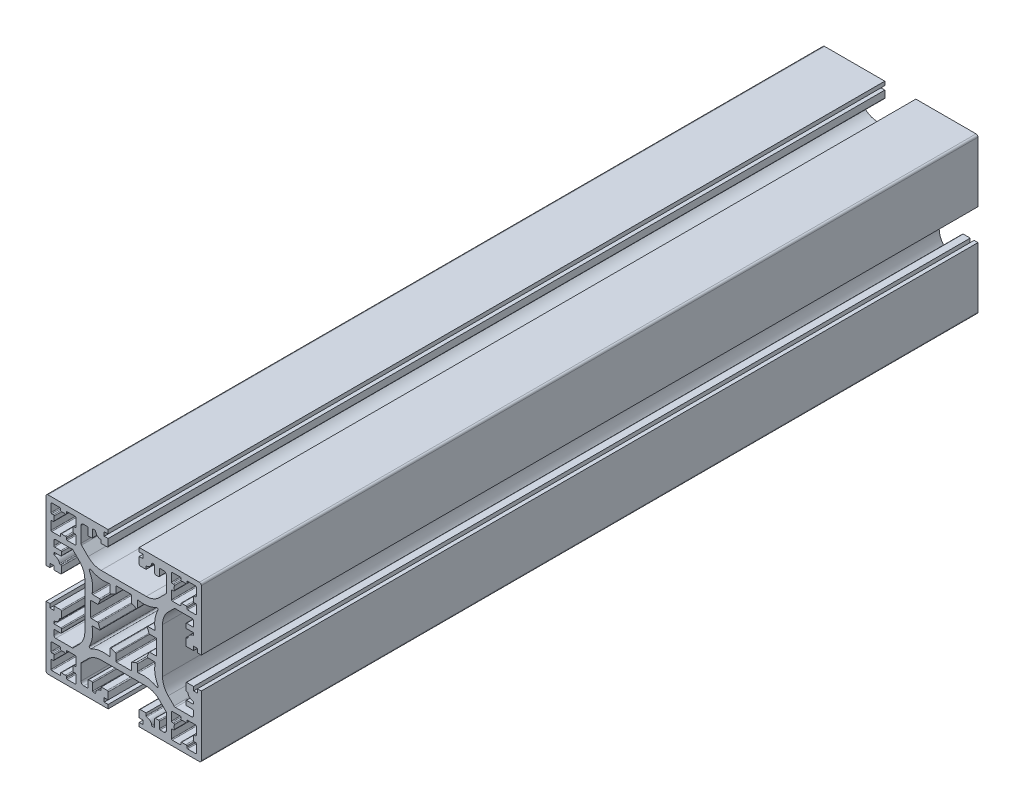
from build123d import *

# Parameters (mm, degrees)
EXTRUDE1_DEPTH = 200


with BuildPart() as part:
    # Sketch1 → Extrude1 (new body)
    with BuildSketch(Plane.XY):
        with BuildLine():
            Line((-18, 9.4), (-18, 10.5))
            ThreePointArc((-18, 10.5), (-17.853553391, 10.853553391), (-17.5, 11))
            Line((-17.5, 11), (-16.25, 11))
            Line((-16.25, 11), (-13.328427125, 11))
            ThreePointArc((-13.328427125, 11), (-13.137085409, 10.961939766), (-12.974873734, 10.853553391))
            Line((-12.974873734, 10.853553391), (-11.464466094, 9.343145751))
            ThreePointArc((-11.464466094, 9.343145751), (-10.380602337, 7.721029006), (-10, 5.807611845))
            Line((-10, 5.807611845), (-10, -5.807611845))
            ThreePointArc((-10, -5.807611845), (-10.380602337, -7.721029006), (-11.464466094, -9.343145751))
            Line((-11.464466094, -9.343145751), (-12.974873734, -10.853553391))
            ThreePointArc((-12.974873734, -10.853553391), (-13.137085409, -10.961939766), (-13.328427125, -11))
            Line((-13.328427125, -11), (-16.25, -11))
            Line((-16.25, -11), (-17.5, -11))
            ThreePointArc((-17.5, -11), (-17.853553391, -10.853553391), (-18, -10.5))
            Line((-18, -10.5), (-18, -9.4))
            ThreePointArc((-18, -9.4), (-17.941421356, -9.258578644), (-17.8, -9.2))
            Line((-17.8, -9.2), (-16.2, -9.2))
            ThreePointArc((-16.2, -9.2), (-16.058578644, -9.141421356), (-16, -9))
            Line((-16, -9), (-16, -8.2))
            ThreePointArc((-16, -8.2), (-16.058578644, -8.058578644), (-16.2, -8))
            Line((-16.2, -8), (-17.8, -8))
            ThreePointArc((-17.8, -8), (-17.941421356, -7.941421356), (-18, -7.8))
            Line((-18, -7.8), (-18, -7.531789047))
            ThreePointArc((-18, -7.531789047), (-17.949481595, -7.398915976), (-17.823447471, -7.333168262))
            ThreePointArc((-17.823447471, -7.333168262), (-16.983327357, -6.948573625), (-16.525924554, -6.145767599))
            ThreePointArc((-16.525924554, -6.145767599), (-16.456281354, -6.03147519), (-16.330156521, -5.986692865))
            Line((-16.330156521, -5.986692865), (-16.2, -5.986692865))
            ThreePointArc((-16.2, -5.986692865), (-16.058578644, -5.928114221), (-16, -5.786692865))
            Line((-16, -5.786692865), (-16, -4.5))
            Line((-16, -4.5), (-16, -4.2))
            ThreePointArc((-16, -4.2), (-16.058578644, -4.058578644), (-16.2, -4))
            Line((-16.2, -4), (-16.5, -4))
            Line((-16.5, -4), (-18, -4))
            Line((-18, -4), (-18, -5))
            Line((-18, -5), (-19, -5))
            Line((-19, -5), (-19, -4))
            Line((-19, -4), (-19.5, -4))
            Line((-19.5, -4), (-20, -4))
            Line((-20, -4), (-20, -4.5))
            Line((-20, -4.5), (-20, -19.5))
            ThreePointArc((-20, -19.5), (-19.853553391, -19.853553391), (-19.5, -20))
            Line((-19.5, -20), (-4, -20))
            Line((-4, -20), (-4, -19))
            Line((-4, -19), (-5, -19))
            Line((-5, -19), (-5, -18))
            Line((-5, -18), (-4, -18))
            Line((-4, -18), (-4, -16.25))
            ThreePointArc((-4, -16.25), (-4.073223305, -16.073223305), (-4.25, -16))
            Line((-4.25, -16), (-5.775096326, -16))
            Line((-5.775096326, -16), (-5.775096326, -16.63645073))
            ThreePointArc((-5.775096326, -16.63645073), (-5.828592677, -16.772600209), (-5.960463134, -16.835914686))
            ThreePointArc((-5.960463134, -16.835914686), (-6.800732332, -17.206772841), (-7.216966157, -18.025514253))
            ThreePointArc((-7.216966157, -18.025514253), (-7.283238985, -18.15017132), (-7.415332039, -18.2))
            Line((-7.415332039, -18.2), (-7.8, -18.2))
            ThreePointArc((-7.8, -18.2), (-7.941421356, -18.141421356), (-8, -18))
            Line((-8, -18), (-8, -16.2))
            ThreePointArc((-8, -16.2), (-8.058578644, -16.058578644), (-8.2, -16))
            Line((-8.2, -16), (-9, -16))
            ThreePointArc((-9, -16), (-9.141421356, -16.058578644), (-9.2, -16.2))
            Line((-9.2, -16.2), (-9.2, -17.8))
            ThreePointArc((-9.2, -17.8), (-9.258578644, -17.941421356), (-9.4, -18))
            Line((-9.4, -18), (-10.3, -18))
            ThreePointArc((-10.3, -18), (-10.794974747, -17.794974747), (-11, -17.3))
            Line((-11, -17.3), (-11, -13.431980515))
            ThreePointArc((-11, -13.431980515), (-10.961939766, -13.240638799), (-10.853553391, -13.078427125))
            Line((-10.853553391, -13.078427125), (-9.166369055, -11.391242789))
            ThreePointArc((-9.166369055, -11.391242789), (-7.625358148, -10.361572221), (-5.807611845, -10))
            Line((-5.807611845, -10), (5.807611845, -10))
            ThreePointArc((5.807611845, -10), (7.625358148, -10.361572221), (9.166369055, -11.391242789))
            Line((9.166369055, -11.391242789), (10.853553391, -13.078427125))
            ThreePointArc((10.853553391, -13.078427125), (10.961939766, -13.240638799), (11, -13.431980515))
            Line((11, -13.431980515), (11, -17.3))
            ThreePointArc((11, -17.3), (10.794974747, -17.794974747), (10.3, -18))
            Line((10.3, -18), (9.4, -18))
            ThreePointArc((9.4, -18), (9.258578644, -17.941421356), (9.2, -17.8))
            Line((9.2, -17.8), (9.2, -16.2))
            ThreePointArc((9.2, -16.2), (9.141421356, -16.058578644), (9, -16))
            Line((9, -16), (8.2, -16))
            ThreePointArc((8.2, -16), (8.058578644, -16.058578644), (8, -16.2))
            Line((8, -16.2), (8, -18))
            ThreePointArc((8, -18), (7.941421356, -18.141421356), (7.8, -18.2))
            Line((7.8, -18.2), (7.415332039, -18.2))
            ThreePointArc((7.415332039, -18.2), (7.283238985, -18.15017132), (7.216966157, -18.025514253))
            ThreePointArc((7.216966157, -18.025514253), (6.800732332, -17.206772841), (5.960463134, -16.835914686))
            ThreePointArc((5.960463134, -16.835914686), (5.828592677, -16.772600209), (5.775096326, -16.63645073))
            Line((5.775096326, -16.63645073), (5.775096326, -16))
            Line((5.775096326, -16), (4.25, -16))
            ThreePointArc((4.25, -16), (4.073223305, -16.073223305), (4, -16.25))
            Line((4, -16.25), (4, -18))
            Line((4, -18), (5, -18))
            Line((5, -18), (5, -19))
            Line((5, -19), (4, -19))
            Line((4, -19), (4, -20))
            Line((4, -20), (19.5, -20))
            ThreePointArc((19.5, -20), (19.853553391, -19.853553391), (20, -19.5))
            Line((20, -19.5), (20, -4.5))
            Line((20, -4.5), (20, -4))
            Line((20, -4), (19.5, -4))
            Line((19.5, -4), (19, -4))
            Line((19, -4), (19, -5))
            Line((19, -5), (18, -5))
            Line((18, -5), (18, -4))
            Line((18, -4), (16.5, -4))
            Line((16.5, -4), (16.2, -4))
            ThreePointArc((16.2, -4), (16.058578644, -4.058578644), (16, -4.2))
            Line((16, -4.2), (16, -4.5))
            Line((16, -4.5), (16, -5.786692865))
            ThreePointArc((16, -5.786692865), (16.058578644, -5.928114221), (16.2, -5.986692865))
            Line((16.2, -5.986692865), (16.330156521, -5.986692865))
            ThreePointArc((16.330156521, -5.986692865), (16.456281354, -6.03147519), (16.525924554, -6.145767599))
            ThreePointArc((16.525924554, -6.145767599), (16.983327357, -6.948573625), (17.823447471, -7.333168262))
            ThreePointArc((17.823447471, -7.333168262), (17.949481595, -7.398915976), (18, -7.531789047))
            Line((18, -7.531789047), (18, -7.8))
            ThreePointArc((18, -7.8), (17.941421356, -7.941421356), (17.8, -8))
            Line((17.8, -8), (16.2, -8))
            ThreePointArc((16.2, -8), (16.058578644, -8.058578644), (16, -8.2))
            Line((16, -8.2), (16, -9))
            ThreePointArc((16, -9), (16.058578644, -9.141421356), (16.2, -9.2))
            Line((16.2, -9.2), (17.8, -9.2))
            ThreePointArc((17.8, -9.2), (17.941421356, -9.258578644), (18, -9.4))
            Line((18, -9.4), (18, -10.5))
            ThreePointArc((18, -10.5), (17.853553391, -10.853553391), (17.5, -11))
            Line((17.5, -11), (16.25, -11))
            Line((16.25, -11), (13.328427125, -11))
            ThreePointArc((13.328427125, -11), (13.137085409, -10.961939766), (12.974873734, -10.853553391))
            Line((12.974873734, -10.853553391), (11.464466094, -9.343145751))
            ThreePointArc((11.464466094, -9.343145751), (10.380602337, -7.721029006), (10, -5.807611845))
            Line((10, -5.807611845), (10, 5.807611845))
            ThreePointArc((10, 5.807611845), (10.380602337, 7.721029006), (11.464466094, 9.343145751))
            Line((11.464466094, 9.343145751), (12.974873734, 10.853553391))
            ThreePointArc((12.974873734, 10.853553391), (13.137085409, 10.961939766), (13.328427125, 11))
            Line((13.328427125, 11), (16.25, 11))
            Line((16.25, 11), (17.5, 11))
            ThreePointArc((17.5, 11), (17.853553391, 10.853553391), (18, 10.5))
            Line((18, 10.5), (18, 9.4))
            ThreePointArc((18, 9.4), (17.941421356, 9.258578644), (17.8, 9.2))
            Line((17.8, 9.2), (16.2, 9.2))
            ThreePointArc((16.2, 9.2), (16.058578644, 9.141421356), (16, 9))
            Line((16, 9), (16, 8.2))
            ThreePointArc((16, 8.2), (16.058578644, 8.058578644), (16.2, 8))
            Line((16.2, 8), (17.8, 8))
            ThreePointArc((17.8, 8), (17.941421356, 7.941421356), (18, 7.8))
            Line((18, 7.8), (18, 7.531789047))
            ThreePointArc((18, 7.531789047), (17.949481595, 7.398915976), (17.823447471, 7.333168262))
            ThreePointArc((17.823447471, 7.333168262), (16.983327357, 6.948573625), (16.525924554, 6.145767599))
            ThreePointArc((16.525924554, 6.145767599), (16.456281354, 6.03147519), (16.330156521, 5.986692865))
            Line((16.330156521, 5.986692865), (16.2, 5.986692865))
            ThreePointArc((16.2, 5.986692865), (16.058578644, 5.928114221), (16, 5.786692865))
            Line((16, 5.786692865), (16, 4.5))
            Line((16, 4.5), (16, 4.2))
            ThreePointArc((16, 4.2), (16.058578644, 4.058578644), (16.2, 4))
            Line((16.2, 4), (16.5, 4))
            Line((16.5, 4), (18, 4))
            Line((18, 4), (18, 5))
            Line((18, 5), (19, 5))
            Line((19, 5), (19, 4))
            Line((19, 4), (19.5, 4))
            Line((19.5, 4), (20, 4))
            Line((20, 4), (20, 4.5))
            Line((20, 4.5), (20, 19.5))
            ThreePointArc((20, 19.5), (19.853553391, 19.853553391), (19.5, 20))
            Line((19.5, 20), (4, 20))
            Line((4, 20), (4, 19))
            Line((4, 19), (5, 19))
            Line((5, 19), (5, 18))
            Line((5, 18), (4, 18))
            Line((4, 18), (4, 16.25))
            ThreePointArc((4, 16.25), (4.073223305, 16.073223305), (4.25, 16))
            Line((4.25, 16), (5.775096326, 16))
            Line((5.775096326, 16), (5.775096326, 16.63645073))
            ThreePointArc((5.775096326, 16.63645073), (5.828592677, 16.772600209), (5.960463134, 16.835914686))
            ThreePointArc((5.960463134, 16.835914686), (6.800732332, 17.206772841), (7.216966157, 18.025514253))
            ThreePointArc((7.216966157, 18.025514253), (7.283238985, 18.15017132), (7.415332039, 18.2))
            Line((7.415332039, 18.2), (7.8, 18.2))
            ThreePointArc((7.8, 18.2), (7.941421356, 18.141421356), (8, 18))
            Line((8, 18), (8, 16.2))
            ThreePointArc((8, 16.2), (8.058578644, 16.058578644), (8.2, 16))
            Line((8.2, 16), (9, 16))
            ThreePointArc((9, 16), (9.141421356, 16.058578644), (9.2, 16.2))
            Line((9.2, 16.2), (9.2, 17.8))
            ThreePointArc((9.2, 17.8), (9.258578644, 17.941421356), (9.4, 18))
            Line((9.4, 18), (10.3, 18))
            ThreePointArc((10.3, 18), (10.794974747, 17.794974747), (11, 17.3))
            Line((11, 17.3), (11, 13.431980515))
            ThreePointArc((11, 13.431980515), (10.961939766, 13.240638799), (10.853553391, 13.078427125))
            Line((10.853553391, 13.078427125), (9.166369055, 11.391242789))
            ThreePointArc((9.166369055, 11.391242789), (7.625358148, 10.361572221), (5.807611845, 10))
            Line((5.807611845, 10), (-5.807611845, 10))
            ThreePointArc((-5.807611845, 10), (-7.625358148, 10.361572221), (-9.166369055, 11.391242789))
            Line((-9.166369055, 11.391242789), (-10.853553391, 13.078427125))
            ThreePointArc((-10.853553391, 13.078427125), (-10.961939766, 13.240638799), (-11, 13.431980515))
            Line((-11, 13.431980515), (-11, 17.3))
            ThreePointArc((-11, 17.3), (-10.794974747, 17.794974747), (-10.3, 18))
            Line((-10.3, 18), (-9.4, 18))
            ThreePointArc((-9.4, 18), (-9.258578644, 17.941421356), (-9.2, 17.8))
            Line((-9.2, 17.8), (-9.2, 16.2))
            ThreePointArc((-9.2, 16.2), (-9.141421356, 16.058578644), (-9, 16))
            Line((-9, 16), (-8.2, 16))
            ThreePointArc((-8.2, 16), (-8.058578644, 16.058578644), (-8, 16.2))
            Line((-8, 16.2), (-8, 18))
            ThreePointArc((-8, 18), (-7.941421356, 18.141421356), (-7.8, 18.2))
            Line((-7.8, 18.2), (-7.415332039, 18.2))
            ThreePointArc((-7.415332039, 18.2), (-7.283238985, 18.15017132), (-7.216966157, 18.025514253))
            ThreePointArc((-7.216966157, 18.025514253), (-6.800732332, 17.206772841), (-5.960463134, 16.835914686))
            ThreePointArc((-5.960463134, 16.835914686), (-5.828592677, 16.772600209), (-5.775096326, 16.63645073))
            Line((-5.775096326, 16.63645073), (-5.775096326, 16))
            Line((-5.775096326, 16), (-4.25, 16))
            ThreePointArc((-4.25, 16), (-4.073223305, 16.073223305), (-4, 16.25))
            Line((-4, 16.25), (-4, 18))
            Line((-4, 18), (-5, 18))
            Line((-5, 18), (-5, 19))
            Line((-5, 19), (-4, 19))
            Line((-4, 19), (-4, 20))
            Line((-4, 20), (-19.5, 20))
            ThreePointArc((-19.5, 20), (-19.853553391, 19.853553391), (-20, 19.5))
            Line((-20, 19.5), (-20, 4.5))
            Line((-20, 4.5), (-20, 4))
            Line((-20, 4), (-19.5, 4))
            Line((-19.5, 4), (-19, 4))
            Line((-19, 4), (-19, 5))
            Line((-19, 5), (-18, 5))
            Line((-18, 5), (-18, 4))
            Line((-18, 4), (-16.5, 4))
            Line((-16.5, 4), (-16.2, 4))
            ThreePointArc((-16.2, 4), (-16.058578644, 4.058578644), (-16, 4.2))
            Line((-16, 4.2), (-16, 4.5))
            Line((-16, 4.5), (-16, 5.786692865))
            ThreePointArc((-16, 5.786692865), (-16.058578644, 5.928114221), (-16.2, 5.986692865))
            Line((-16.2, 5.986692865), (-16.330156521, 5.986692865))
            ThreePointArc((-16.330156521, 5.986692865), (-16.456281354, 6.03147519), (-16.525924554, 6.145767599))
            ThreePointArc((-16.525924554, 6.145767599), (-16.983327357, 6.948573625), (-17.823447471, 7.333168262))
            ThreePointArc((-17.823447471, 7.333168262), (-17.949481595, 7.398915976), (-18, 7.531789047))
            Line((-18, 7.531789047), (-18, 7.8))
            ThreePointArc((-18, 7.8), (-17.941421356, 7.941421356), (-17.8, 8))
            Line((-17.8, 8), (-16.2, 8))
            ThreePointArc((-16.2, 8), (-16.058578644, 8.058578644), (-16, 8.2))
            Line((-16, 8.2), (-16, 9))
            ThreePointArc((-16, 9), (-16.058578644, 9.141421356), (-16.2, 9.2))
            Line((-16.2, 9.2), (-17.8, 9.2))
            ThreePointArc((-17.8, 9.2), (-17.941421356, 9.258578644), (-18, 9.4))
        make_face()
        with BuildLine():
            Line((1.8, 8.5), (-1.8, 8.5))
            ThreePointArc((-1.8, 8.5), (-1.941421356, 8.441421356), (-2, 8.3))
            Line((-2, 8.3), (-2, 6.697947447))
            ThreePointArc((-2, 6.697947447), (-2.038008844, 6.580649257), (-2.137588652, 6.507934753))
            ThreePointArc((-2.137588652, 6.507934753), (-2.681640734, 6.303277162), (-3.206382979, 6.053231219))
            ThreePointArc((-3.206382979, 6.053231219), (-3.403142125, 6.05861533), (-3.5, 6.229967897))
            Line((-3.5, 6.229967897), (-3.5, 7.919878854))
            ThreePointArc((-3.5, 7.919878854), (-3.572914811, 8.074311217), (-3.738493547, 8.116139514))
            ThreePointArc((-3.738493547, 8.116139514), (-6.145812945, 8.065992143), (-8.427707326, 8.834535885))
            ThreePointArc((-8.427707326, 8.834535885), (-8.783065344, 8.783065344), (-8.834535885, 8.427707326))
            ThreePointArc((-8.834535885, 8.427707326), (-8.065992143, 6.145812945), (-8.116139514, 3.738493547))
            ThreePointArc((-8.116139514, 3.738493547), (-8.074311217, 3.572914811), (-7.919878854, 3.5))
            Line((-7.919878854, 3.5), (-6.229967897, 3.5))
            ThreePointArc((-6.229967897, 3.5), (-6.05861533, 3.403142125), (-6.053231219, 3.206382979))
            ThreePointArc((-6.053231219, 3.206382979), (-6.303277162, 2.681640734), (-6.507934753, 2.137588652))
            ThreePointArc((-6.507934753, 2.137588652), (-6.580649257, 2.038008844), (-6.697947447, 2))
            Line((-6.697947447, 2), (-8.3, 2))
            ThreePointArc((-8.3, 2), (-8.441421356, 1.941421356), (-8.5, 1.8))
            Line((-8.5, 1.8), (-8.5, -1.8))
            ThreePointArc((-8.5, -1.8), (-8.441421356, -1.941421356), (-8.3, -2))
            Line((-8.3, -2), (-6.697947447, -2))
            ThreePointArc((-6.697947447, -2), (-6.580649257, -2.038008844), (-6.507934753, -2.137588652))
            ThreePointArc((-6.507934753, -2.137588652), (-6.303277162, -2.681640734), (-6.053231219, -3.206382979))
            ThreePointArc((-6.053231219, -3.206382979), (-6.05861533, -3.403142125), (-6.229967897, -3.5))
            Line((-6.229967897, -3.5), (-7.919878854, -3.5))
            ThreePointArc((-7.919878854, -3.5), (-8.074311217, -3.572914811), (-8.116139514, -3.738493547))
            ThreePointArc((-8.116139514, -3.738493547), (-8.065992143, -6.145812945), (-8.834535885, -8.427707326))
            ThreePointArc((-8.834535885, -8.427707326), (-8.783065344, -8.783065344), (-8.427707326, -8.834535885))
            ThreePointArc((-8.427707326, -8.834535885), (-6.145812945, -8.065992143), (-3.738493547, -8.116139514))
            ThreePointArc((-3.738493547, -8.116139514), (-3.572914811, -8.074311217), (-3.5, -7.919878854))
            Line((-3.5, -7.919878854), (-3.5, -6.229967897))
            ThreePointArc((-3.5, -6.229967897), (-3.403142125, -6.05861533), (-3.206382979, -6.053231219))
            ThreePointArc((-3.206382979, -6.053231219), (-2.681640734, -6.303277162), (-2.137588652, -6.507934753))
            ThreePointArc((-2.137588652, -6.507934753), (-2.038008844, -6.580649257), (-2, -6.697947447))
            Line((-2, -6.697947447), (-2, -8.3))
            ThreePointArc((-2, -8.3), (-1.941421356, -8.441421356), (-1.8, -8.5))
            Line((-1.8, -8.5), (1.8, -8.5))
            ThreePointArc((1.8, -8.5), (1.941421356, -8.441421356), (2, -8.3))
            Line((2, -8.3), (2, -6.697947447))
            ThreePointArc((2, -6.697947447), (2.038008844, -6.580649257), (2.137588652, -6.507934753))
            ThreePointArc((2.137588652, -6.507934753), (2.681640734, -6.303277162), (3.206382979, -6.053231219))
            ThreePointArc((3.206382979, -6.053231219), (3.403142125, -6.05861533), (3.5, -6.229967897))
            Line((3.5, -6.229967897), (3.5, -7.919878854))
            ThreePointArc((3.5, -7.919878854), (3.572914811, -8.074311217), (3.738493547, -8.116139514))
            ThreePointArc((3.738493547, -8.116139514), (6.145812945, -8.065992143), (8.427707326, -8.834535885))
            ThreePointArc((8.427707326, -8.834535885), (8.783065344, -8.783065344), (8.834535885, -8.427707326))
            ThreePointArc((8.834535885, -8.427707326), (8.065992143, -6.145812945), (8.116139514, -3.738493547))
            ThreePointArc((8.116139514, -3.738493547), (8.074311217, -3.572914811), (7.919878854, -3.5))
            Line((7.919878854, -3.5), (6.229967897, -3.5))
            ThreePointArc((6.229967897, -3.5), (6.05861533, -3.403142125), (6.053231219, -3.206382979))
            ThreePointArc((6.053231219, -3.206382979), (6.303277162, -2.681640734), (6.507934753, -2.137588652))
            ThreePointArc((6.507934753, -2.137588652), (6.580649257, -2.038008844), (6.697947447, -2))
            Line((6.697947447, -2), (8.3, -2))
            ThreePointArc((8.3, -2), (8.441421356, -1.941421356), (8.5, -1.8))
            Line((8.5, -1.8), (8.5, 1.8))
            ThreePointArc((8.5, 1.8), (8.441421356, 1.941421356), (8.3, 2))
            Line((8.3, 2), (6.697947447, 2))
            ThreePointArc((6.697947447, 2), (6.580649257, 2.038008844), (6.507934753, 2.137588652))
            ThreePointArc((6.507934753, 2.137588652), (6.303277162, 2.681640734), (6.053231219, 3.206382979))
            ThreePointArc((6.053231219, 3.206382979), (6.05861533, 3.403142125), (6.229967897, 3.5))
            Line((6.229967897, 3.5), (7.919878854, 3.5))
            ThreePointArc((7.919878854, 3.5), (8.074311217, 3.572914811), (8.116139514, 3.738493547))
            ThreePointArc((8.116139514, 3.738493547), (8.065992143, 6.145812945), (8.834535885, 8.427707326))
            ThreePointArc((8.834535885, 8.427707326), (8.783065344, 8.783065344), (8.427707326, 8.834535885))
            ThreePointArc((8.427707326, 8.834535885), (6.145812945, 8.065992143), (3.738493547, 8.116139514))
            ThreePointArc((3.738493547, 8.116139514), (3.572914811, 8.074311217), (3.5, 7.919878854))
            Line((3.5, 7.919878854), (3.5, 6.229967897))
            ThreePointArc((3.5, 6.229967897), (3.403142125, 6.05861533), (3.206382979, 6.053231219))
            ThreePointArc((3.206382979, 6.053231219), (2.681640734, 6.303277162), (2.137588652, 6.507934753))
            ThreePointArc((2.137588652, 6.507934753), (2.038008844, 6.580649257), (2, 6.697947447))
            Line((2, 6.697947447), (2, 8.3))
            ThreePointArc((2, 8.3), (1.941421356, 8.441421356), (1.8, 8.5))
        make_face(mode=Mode.SUBTRACT)
        with BuildLine():
            Line((-18.5, 18.7), (-16.45, 18.7))
            ThreePointArc((-16.45, 18.7), (-16.308578644, 18.641421356), (-16.25, 18.5))
            Line((-16.25, 18.5), (-16.25, 18.143387978))
            ThreePointArc((-16.25, 18.143387978), (-16.176197963, 17.988229755), (-16.009259259, 17.947581461))
            ThreePointArc((-16.009259259, 17.947581461), (-15.5, 18), (-14.990740741, 17.947581461))
            ThreePointArc((-14.990740741, 17.947581461), (-14.823802037, 17.988229755), (-14.75, 18.143387978))
            Line((-14.75, 18.143387978), (-14.75, 18.5))
            ThreePointArc((-14.75, 18.5), (-14.691421356, 18.641421356), (-14.55, 18.7))
            Line((-14.55, 18.7), (-12.5, 18.7))
            ThreePointArc((-12.5, 18.7), (-12.358578644, 18.641421356), (-12.3, 18.5))
            Line((-12.3, 18.5), (-12.3, 16.45))
            ThreePointArc((-12.3, 16.45), (-12.358578644, 16.308578644), (-12.5, 16.25))
            Line((-12.5, 16.25), (-12.856612022, 16.25))
            ThreePointArc((-12.856612022, 16.25), (-13.011770245, 16.176197963), (-13.052418539, 16.009259259))
            ThreePointArc((-13.052418539, 16.009259259), (-13, 15.5), (-13.052418539, 14.990740741))
            ThreePointArc((-13.052418539, 14.990740741), (-13.011770245, 14.823802037), (-12.856612022, 14.75))
            Line((-12.856612022, 14.75), (-12.5, 14.75))
            ThreePointArc((-12.5, 14.75), (-12.358578644, 14.691421356), (-12.3, 14.55))
            Line((-12.3, 14.55), (-12.3, 12.5))
            ThreePointArc((-12.3, 12.5), (-12.358578644, 12.358578644), (-12.5, 12.3))
            Line((-12.5, 12.3), (-14.55, 12.3))
            ThreePointArc((-14.55, 12.3), (-14.691421356, 12.358578644), (-14.75, 12.5))
            Line((-14.75, 12.5), (-14.75, 12.856612022))
            ThreePointArc((-14.75, 12.856612022), (-14.823802037, 13.011770245), (-14.990740741, 13.052418539))
            ThreePointArc((-14.990740741, 13.052418539), (-15.5, 13), (-16.009259259, 13.052418539))
            ThreePointArc((-16.009259259, 13.052418539), (-16.176197963, 13.011770245), (-16.25, 12.856612022))
            Line((-16.25, 12.856612022), (-16.25, 12.5))
            ThreePointArc((-16.25, 12.5), (-16.308578644, 12.358578644), (-16.45, 12.3))
            Line((-16.45, 12.3), (-18.5, 12.3))
            ThreePointArc((-18.5, 12.3), (-18.641421356, 12.358578644), (-18.7, 12.5))
            Line((-18.7, 12.5), (-18.7, 14.55))
            ThreePointArc((-18.7, 14.55), (-18.641421356, 14.691421356), (-18.5, 14.75))
            Line((-18.5, 14.75), (-18.143387978, 14.75))
            ThreePointArc((-18.143387978, 14.75), (-17.988229755, 14.823802037), (-17.947581461, 14.990740741))
            ThreePointArc((-17.947581461, 14.990740741), (-18, 15.5), (-17.947581461, 16.009259259))
            ThreePointArc((-17.947581461, 16.009259259), (-17.988229755, 16.176197963), (-18.143387978, 16.25))
            Line((-18.143387978, 16.25), (-18.5, 16.25))
            ThreePointArc((-18.5, 16.25), (-18.641421356, 16.308578644), (-18.7, 16.45))
            Line((-18.7, 16.45), (-18.7, 18.5))
            ThreePointArc((-18.7, 18.5), (-18.641421356, 18.641421356), (-18.5, 18.7))
        make_face(mode=Mode.SUBTRACT)
        with BuildLine():
            Line((12.3, 14.55), (12.3, 12.5))
            ThreePointArc((12.3, 12.5), (12.358578644, 12.358578644), (12.5, 12.3))
            Line((12.5, 12.3), (14.55, 12.3))
            ThreePointArc((14.55, 12.3), (14.691421356, 12.358578644), (14.75, 12.5))
            Line((14.75, 12.5), (14.75, 12.856612022))
            ThreePointArc((14.75, 12.856612022), (14.823802037, 13.011770245), (14.990740741, 13.052418539))
            ThreePointArc((14.990740741, 13.052418539), (15.5, 13), (16.009259259, 13.052418539))
            ThreePointArc((16.009259259, 13.052418539), (16.176197963, 13.011770245), (16.25, 12.856612022))
            Line((16.25, 12.856612022), (16.25, 12.5))
            ThreePointArc((16.25, 12.5), (16.308578644, 12.358578644), (16.45, 12.3))
            Line((16.45, 12.3), (18.5, 12.3))
            ThreePointArc((18.5, 12.3), (18.641421356, 12.358578644), (18.7, 12.5))
            Line((18.7, 12.5), (18.7, 14.55))
            ThreePointArc((18.7, 14.55), (18.641421356, 14.691421356), (18.5, 14.75))
            Line((18.5, 14.75), (18.143387978, 14.75))
            ThreePointArc((18.143387978, 14.75), (17.988229755, 14.823802037), (17.947581461, 14.990740741))
            ThreePointArc((17.947581461, 14.990740741), (18, 15.5), (17.947581461, 16.009259259))
            ThreePointArc((17.947581461, 16.009259259), (17.988229755, 16.176197963), (18.143387978, 16.25))
            Line((18.143387978, 16.25), (18.5, 16.25))
            ThreePointArc((18.5, 16.25), (18.641421356, 16.308578644), (18.7, 16.45))
            Line((18.7, 16.45), (18.7, 18.5))
            ThreePointArc((18.7, 18.5), (18.641421356, 18.641421356), (18.5, 18.7))
            Line((18.5, 18.7), (16.45, 18.7))
            ThreePointArc((16.45, 18.7), (16.308578644, 18.641421356), (16.25, 18.5))
            Line((16.25, 18.5), (16.25, 18.143387978))
            ThreePointArc((16.25, 18.143387978), (16.176197963, 17.988229755), (16.009259259, 17.947581461))
            ThreePointArc((16.009259259, 17.947581461), (15.5, 18), (14.990740741, 17.947581461))
            ThreePointArc((14.990740741, 17.947581461), (14.823802037, 17.988229755), (14.75, 18.143387978))
            Line((14.75, 18.143387978), (14.75, 18.5))
            ThreePointArc((14.75, 18.5), (14.691421356, 18.641421356), (14.55, 18.7))
            Line((14.55, 18.7), (12.5, 18.7))
            ThreePointArc((12.5, 18.7), (12.358578644, 18.641421356), (12.3, 18.5))
            Line((12.3, 18.5), (12.3, 16.45))
            ThreePointArc((12.3, 16.45), (12.358578644, 16.308578644), (12.5, 16.25))
            Line((12.5, 16.25), (12.856612022, 16.25))
            ThreePointArc((12.856612022, 16.25), (13.011770245, 16.176197963), (13.052418539, 16.009259259))
            ThreePointArc((13.052418539, 16.009259259), (13, 15.5), (13.052418539, 14.990740741))
            ThreePointArc((13.052418539, 14.990740741), (13.011770245, 14.823802037), (12.856612022, 14.75))
            Line((12.856612022, 14.75), (12.5, 14.75))
            ThreePointArc((12.5, 14.75), (12.358578644, 14.691421356), (12.3, 14.55))
        make_face(mode=Mode.SUBTRACT)
        with BuildLine():
            Line((18.5, -18.7), (16.45, -18.7))
            ThreePointArc((16.45, -18.7), (16.308578644, -18.641421356), (16.25, -18.5))
            Line((16.25, -18.5), (16.25, -18.143387978))
            ThreePointArc((16.25, -18.143387978), (16.176197963, -17.988229755), (16.009259259, -17.947581461))
            ThreePointArc((16.009259259, -17.947581461), (15.5, -18), (14.990740741, -17.947581461))
            ThreePointArc((14.990740741, -17.947581461), (14.823802037, -17.988229755), (14.75, -18.143387978))
            Line((14.75, -18.143387978), (14.75, -18.5))
            ThreePointArc((14.75, -18.5), (14.691421356, -18.641421356), (14.55, -18.7))
            Line((14.55, -18.7), (12.5, -18.7))
            ThreePointArc((12.5, -18.7), (12.358578644, -18.641421356), (12.3, -18.5))
            Line((12.3, -18.5), (12.3, -16.45))
            ThreePointArc((12.3, -16.45), (12.358578644, -16.308578644), (12.5, -16.25))
            Line((12.5, -16.25), (12.856612022, -16.25))
            ThreePointArc((12.856612022, -16.25), (13.011770245, -16.176197963), (13.052418539, -16.009259259))
            ThreePointArc((13.052418539, -16.009259259), (13, -15.5), (13.052418539, -14.990740741))
            ThreePointArc((13.052418539, -14.990740741), (13.011770245, -14.823802037), (12.856612022, -14.75))
            Line((12.856612022, -14.75), (12.5, -14.75))
            ThreePointArc((12.5, -14.75), (12.358578644, -14.691421356), (12.3, -14.55))
            Line((12.3, -14.55), (12.3, -12.5))
            ThreePointArc((12.3, -12.5), (12.358578644, -12.358578644), (12.5, -12.3))
            Line((12.5, -12.3), (14.55, -12.3))
            ThreePointArc((14.55, -12.3), (14.691421356, -12.358578644), (14.75, -12.5))
            Line((14.75, -12.5), (14.75, -12.856612022))
            ThreePointArc((14.75, -12.856612022), (14.823802037, -13.011770245), (14.990740741, -13.052418539))
            ThreePointArc((14.990740741, -13.052418539), (15.5, -13), (16.009259259, -13.052418539))
            ThreePointArc((16.009259259, -13.052418539), (16.176197963, -13.011770245), (16.25, -12.856612022))
            Line((16.25, -12.856612022), (16.25, -12.5))
            ThreePointArc((16.25, -12.5), (16.308578644, -12.358578644), (16.45, -12.3))
            Line((16.45, -12.3), (18.5, -12.3))
            ThreePointArc((18.5, -12.3), (18.641421356, -12.358578644), (18.7, -12.5))
            Line((18.7, -12.5), (18.7, -14.55))
            ThreePointArc((18.7, -14.55), (18.641421356, -14.691421356), (18.5, -14.75))
            Line((18.5, -14.75), (18.143387978, -14.75))
            ThreePointArc((18.143387978, -14.75), (17.988229755, -14.823802037), (17.947581461, -14.990740741))
            ThreePointArc((17.947581461, -14.990740741), (18, -15.5), (17.947581461, -16.009259259))
            ThreePointArc((17.947581461, -16.009259259), (17.988229755, -16.176197963), (18.143387978, -16.25))
            Line((18.143387978, -16.25), (18.5, -16.25))
            ThreePointArc((18.5, -16.25), (18.641421356, -16.308578644), (18.7, -16.45))
            Line((18.7, -16.45), (18.7, -18.5))
            ThreePointArc((18.7, -18.5), (18.641421356, -18.641421356), (18.5, -18.7))
        make_face(mode=Mode.SUBTRACT)
        with BuildLine():
            Line((-12.3, -14.55), (-12.3, -12.5))
            ThreePointArc((-12.3, -12.5), (-12.358578644, -12.358578644), (-12.5, -12.3))
            Line((-12.5, -12.3), (-14.55, -12.3))
            ThreePointArc((-14.55, -12.3), (-14.691421356, -12.358578644), (-14.75, -12.5))
            Line((-14.75, -12.5), (-14.75, -12.856612022))
            ThreePointArc((-14.75, -12.856612022), (-14.823802037, -13.011770245), (-14.990740741, -13.052418539))
            ThreePointArc((-14.990740741, -13.052418539), (-15.5, -13), (-16.009259259, -13.052418539))
            ThreePointArc((-16.009259259, -13.052418539), (-16.176197963, -13.011770245), (-16.25, -12.856612022))
            Line((-16.25, -12.856612022), (-16.25, -12.5))
            ThreePointArc((-16.25, -12.5), (-16.308578644, -12.358578644), (-16.45, -12.3))
            Line((-16.45, -12.3), (-18.5, -12.3))
            ThreePointArc((-18.5, -12.3), (-18.641421356, -12.358578644), (-18.7, -12.5))
            Line((-18.7, -12.5), (-18.7, -14.55))
            ThreePointArc((-18.7, -14.55), (-18.641421356, -14.691421356), (-18.5, -14.75))
            Line((-18.5, -14.75), (-18.143387978, -14.75))
            ThreePointArc((-18.143387978, -14.75), (-17.988229755, -14.823802037), (-17.947581461, -14.990740741))
            ThreePointArc((-17.947581461, -14.990740741), (-18, -15.5), (-17.947581461, -16.009259259))
            ThreePointArc((-17.947581461, -16.009259259), (-17.988229755, -16.176197963), (-18.143387978, -16.25))
            Line((-18.143387978, -16.25), (-18.5, -16.25))
            ThreePointArc((-18.5, -16.25), (-18.641421356, -16.308578644), (-18.7, -16.45))
            Line((-18.7, -16.45), (-18.7, -18.5))
            ThreePointArc((-18.7, -18.5), (-18.641421356, -18.641421356), (-18.5, -18.7))
            Line((-18.5, -18.7), (-16.45, -18.7))
            ThreePointArc((-16.45, -18.7), (-16.308578644, -18.641421356), (-16.25, -18.5))
            Line((-16.25, -18.5), (-16.25, -18.143387978))
            ThreePointArc((-16.25, -18.143387978), (-16.176197963, -17.988229755), (-16.009259259, -17.947581461))
            ThreePointArc((-16.009259259, -17.947581461), (-15.5, -18), (-14.990740741, -17.947581461))
            ThreePointArc((-14.990740741, -17.947581461), (-14.823802037, -17.988229755), (-14.75, -18.143387978))
            Line((-14.75, -18.143387978), (-14.75, -18.5))
            ThreePointArc((-14.75, -18.5), (-14.691421356, -18.641421356), (-14.55, -18.7))
            Line((-14.55, -18.7), (-12.5, -18.7))
            ThreePointArc((-12.5, -18.7), (-12.358578644, -18.641421356), (-12.3, -18.5))
            Line((-12.3, -18.5), (-12.3, -16.45))
            ThreePointArc((-12.3, -16.45), (-12.358578644, -16.308578644), (-12.5, -16.25))
            Line((-12.5, -16.25), (-12.856612022, -16.25))
            ThreePointArc((-12.856612022, -16.25), (-13.011770245, -16.176197963), (-13.052418539, -16.009259259))
            ThreePointArc((-13.052418539, -16.009259259), (-13, -15.5), (-13.052418539, -14.990740741))
            ThreePointArc((-13.052418539, -14.990740741), (-13.011770245, -14.823802037), (-12.856612022, -14.75))
            Line((-12.856612022, -14.75), (-12.5, -14.75))
            ThreePointArc((-12.5, -14.75), (-12.358578644, -14.691421356), (-12.3, -14.55))
        make_face(mode=Mode.SUBTRACT)
    extrude(amount=-EXTRUDE1_DEPTH)


solid = part.part
